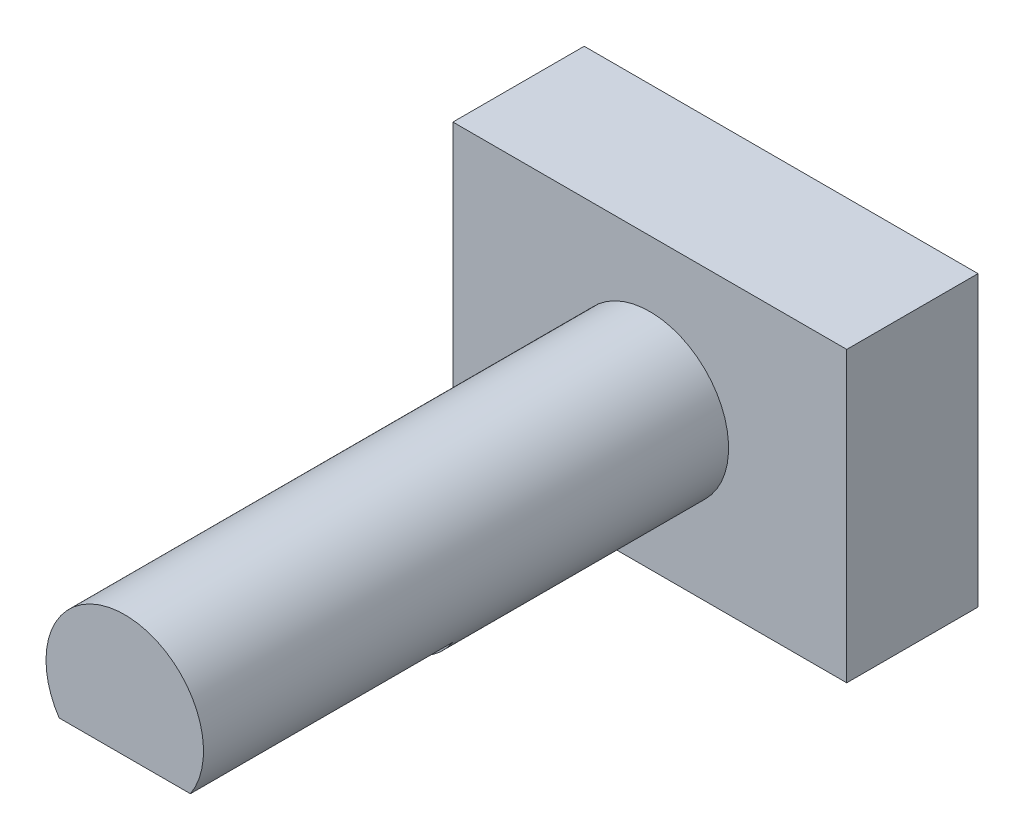
from build123d import *

# Parameters (mm, degrees)
ESQUISSE1_W             = 15
ESQUISSE1_H             = 11
BOSS_EXTRU_1_DEPTH      = 5
ESQUISSE2_R             = 3
BOSS_EXTRU_2_DEPTH      = 20
ENL_V_MAT_EXTRU_1_DEPTH = 10


with BuildPart() as part:
    # Esquisse1 → Boss.-Extru.1 (new body)
    with BuildSketch(Plane.XY):
        Rectangle(ESQUISSE1_W, ESQUISSE1_H)
    extrude(amount=BOSS_EXTRU_1_DEPTH)

    # Esquisse2 → Boss.-Extru.2 (add)
    with BuildSketch(Plane.XY.offset(5)):
        Circle(ESQUISSE2_R)
    extrude(amount=BOSS_EXTRU_2_DEPTH)

    # Esquisse3 → Enlèv. mat.-Extru.1 (cut)
    with BuildSketch(Plane.XY.offset(25)):
        with BuildLine():
            Line((-2.5, -1.658312395), (2.5, -1.658312395))
            ThreePointArc((2.5, -1.658312395), (0, -3), (-2.5, -1.658312395))
        make_face()
    extrude(amount=-ENL_V_MAT_EXTRU_1_DEPTH, mode=Mode.SUBTRACT)


solid = part.part
